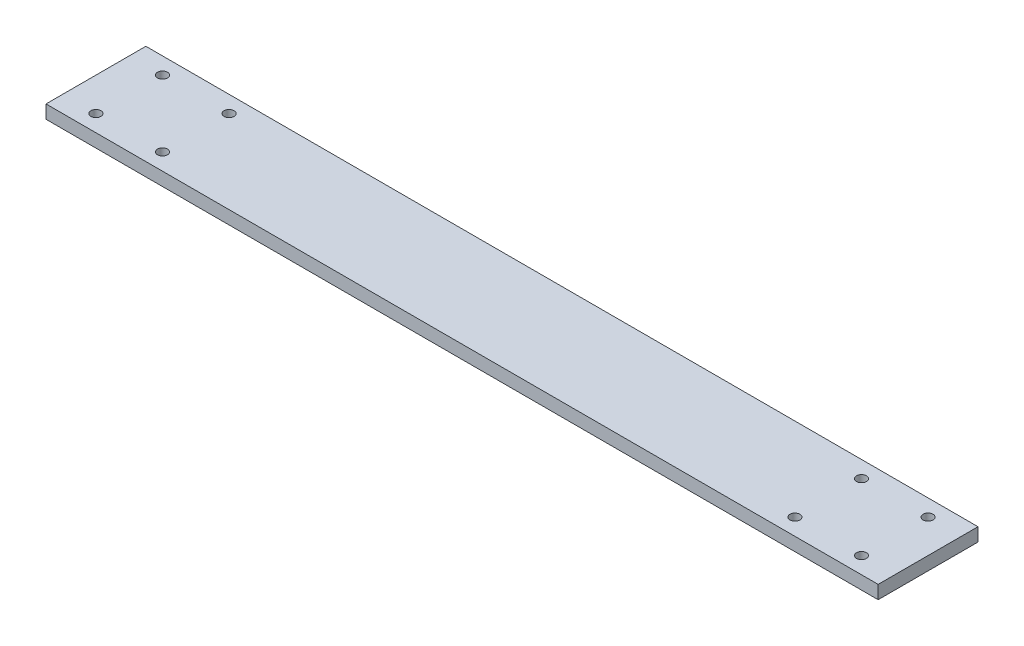
from build123d import *

# Parameters (mm, degrees)
SKIZZE1_W                       = 250
SKIZZE1_H                       = 30
SKIZZE1_R                       = 1.5
AUFSATZ_LINEAR_AUSTRAGEN1_DEPTH = 4


with BuildPart() as part:
    # Skizze1 → Aufsatz-Linear austragen1 (new body)
    with BuildSketch(Plane(origin=(0, 0, 0), x_dir=(1, 0, 0), z_dir=(0, 1, 0))):
        Rectangle(SKIZZE1_W, SKIZZE1_H)
        with Locations((-115, 10)):
            Circle(SKIZZE1_R, mode=Mode.SUBTRACT)
        with Locations((-115, -10)):
            Circle(SKIZZE1_R, mode=Mode.SUBTRACT)
        with Locations((-95, -10)):
            Circle(SKIZZE1_R, mode=Mode.SUBTRACT)
        with Locations((-95, 10)):
            Circle(SKIZZE1_R, mode=Mode.SUBTRACT)
        with Locations((95, -10)):
            Circle(SKIZZE1_R, mode=Mode.SUBTRACT)
        with Locations((115, -10)):
            Circle(SKIZZE1_R, mode=Mode.SUBTRACT)
        with Locations((115, 10)):
            Circle(SKIZZE1_R, mode=Mode.SUBTRACT)
        with Locations((95, 10)):
            Circle(SKIZZE1_R, mode=Mode.SUBTRACT)
    extrude(amount=AUFSATZ_LINEAR_AUSTRAGEN1_DEPTH)


solid = part.part
